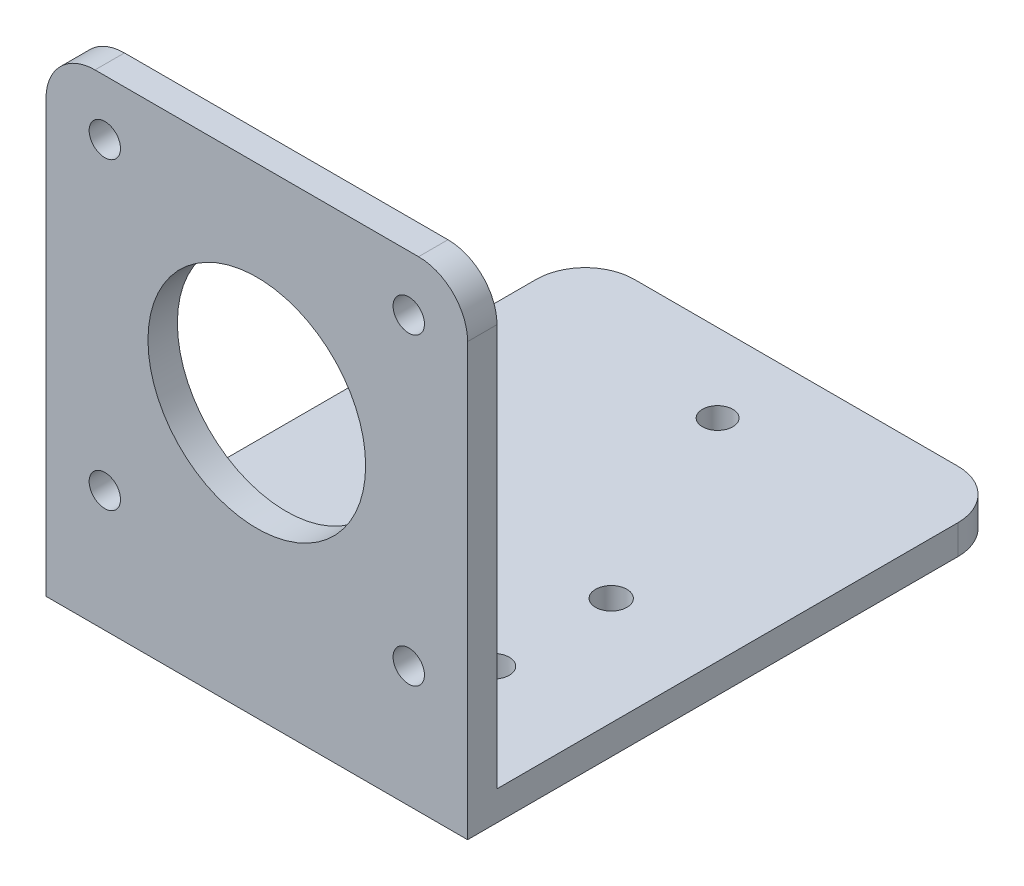
from build123d import *

# Parameters (mm, degrees)
SKETCH_3_W          = 43
SKETCH_3_H          = 49
EXTRUDE_2_DEPTH     = 3
SKETCH_6_R          = 11.1
SKETCH_6_R_2        = 1.6
CUT_EXTRUDE_2_DEPTH = 45
SKETCH_7_W          = 43
SKETCH_7_H          = 3
EXTRUDE_4_DEPTH     = 52
SKETCH_8_R          = 1.6
SKETCH_8_R_2        = 1.55
CUT_EXTRUDE_3_DEPTH = 45
FILLET_1_R          = 5


with BuildPart() as part:
    # 草图3 → 凸台-拉伸2 (new body)
    with BuildSketch(Plane.XY):
        with Locations((21.5, -24.5)):
            Rectangle(SKETCH_3_W, SKETCH_3_H)
    extrude(amount=EXTRUDE_2_DEPTH)

    # 草图6 → 切除-拉伸2 (cut)
    with BuildSketch(Plane(origin=(0, 0, 0), x_dir=(-1, 0, 0), z_dir=(0, 0, -1))):
        with Locations((-21.5, -21.15)):
            Circle(SKETCH_6_R)
        with Locations((-37, -5.65)):
            Circle(SKETCH_6_R_2)
        with Locations((-6, -5.65)):
            Circle(SKETCH_6_R_2)
        with Locations((-6, -36.65)):
            Circle(SKETCH_6_R_2)
        with Locations((-37, -36.65)):
            Circle(SKETCH_6_R_2)
    extrude(amount=-CUT_EXTRUDE_2_DEPTH, mode=Mode.SUBTRACT)

    # 草图7 → 凸台-拉伸4 (add)
    with BuildSketch(Plane(origin=(0, 0, 0), x_dir=(-1, 0, 0), z_dir=(0, 0, -1))):
        with Locations((-21.5, -47.5)):
            Rectangle(SKETCH_7_W, SKETCH_7_H)
    extrude(amount=EXTRUDE_4_DEPTH)

    # 草图8 → 切除-拉伸3 (cut)
    with BuildSketch(Plane(origin=(0, -46, 0), x_dir=(1, 0, 0), z_dir=(0, 1, 0))):
        with Locations((11, 10.65)):
            Circle(SKETCH_8_R)
        with Locations((11, 22.65)):
            Circle(SKETCH_8_R)
        with Locations((32, 10.65)):
            Circle(SKETCH_8_R)
        with Locations((32, 22.65)):
            Circle(SKETCH_8_R)
        with Locations((21.5, 44)):
            Circle(SKETCH_8_R_2)
    extrude(amount=-CUT_EXTRUDE_3_DEPTH, mode=Mode.SUBTRACT)

    # 圆角1
    fillet_1_edges = [part.edges().sort_by_distance(p)[0] for p in [
        (43, -47.5, -52),
        (0, -47.5, -52),
        (0, 0, 1.5),
        (43, 0, 1.5),
    ]]
    fillet(fillet_1_edges, radius=FILLET_1_R)


solid = part.part
